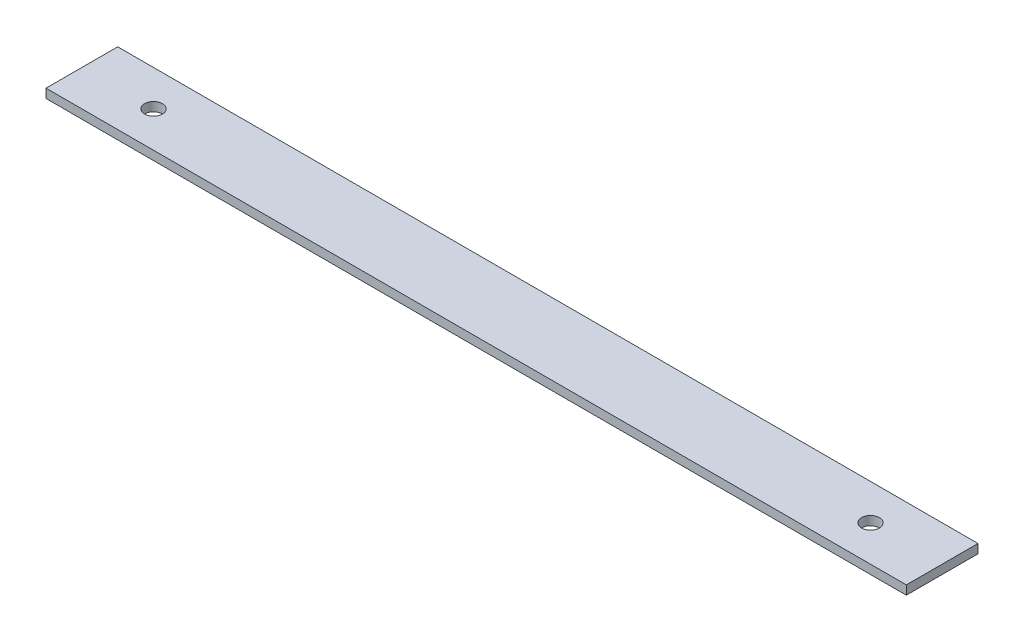
from build123d import *

# Parameters (mm, degrees)
SKETCH1_W           = 304.8
SKETCH1_H           = 25.4
BOSS_EXTRUDE1_DEPTH = 3.175
SKETCH2_R           = 3.175
CUT_EXTRUDE1_DEPTH  = 4.175


with BuildPart() as part:
    # Sketch1 → Boss-Extrude1 (new body)
    with BuildSketch(Plane(origin=(0, 0, 0), x_dir=(1, 0, 0), z_dir=(0, 1, 0))):
        with Locations((152.4, 12.7)):
            Rectangle(SKETCH1_W, SKETCH1_H)
    extrude(amount=BOSS_EXTRUDE1_DEPTH)

    # Sketch2 → Cut-Extrude1 (cut, through all)
    with BuildSketch(Plane(origin=(0, 3.175, 0), x_dir=(1, 0, 0), z_dir=(0, 1, 0))):
        with Locations((279.4, 12.7)):
            Circle(SKETCH2_R)
        with Locations((25.4, 12.7)):
            Circle(SKETCH2_R)
    extrude(amount=-CUT_EXTRUDE1_DEPTH, mode=Mode.SUBTRACT)


solid = part.part
